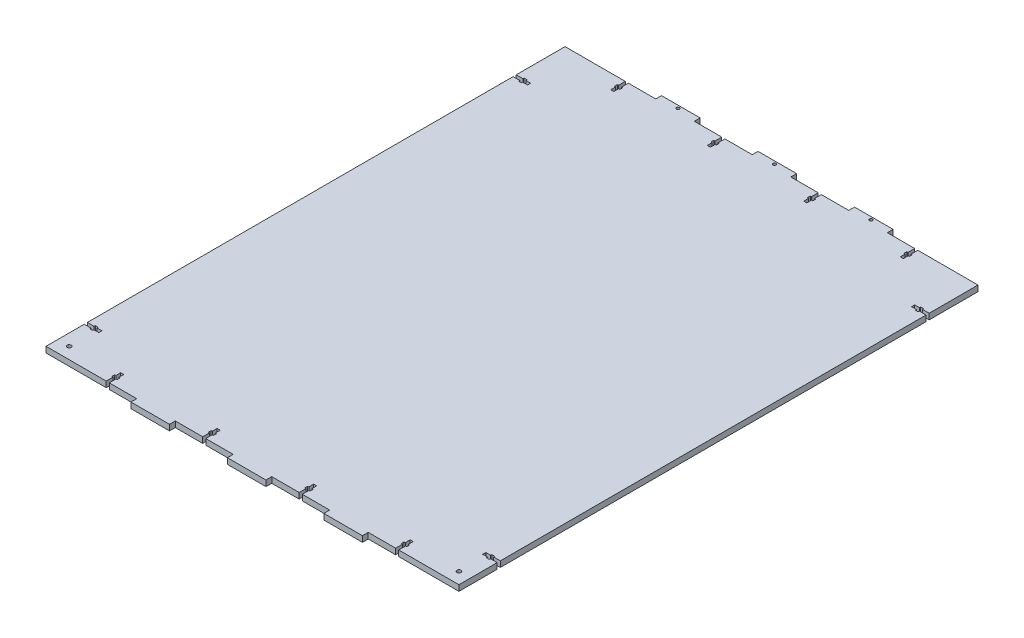
from build123d import *

# Parameters (mm, degrees)
SKETCH1_W           = 428
SKETCH1_H           = 538
BOSS_EXTRUDE1_DEPTH = 6
SKETCH2_W           = 40
SKETCH2_H           = 6
BOSS_EXTRUDE2_DEPTH = 6
SKETCH3_R           = 1.6
SKETCH3_R_2         = 2.1
CUT_EXTRUDE1_DEPTH  = 7


with BuildPart() as part:
    # Sketch1 → Boss-Extrude1 (new body)
    with BuildSketch(Plane(origin=(0, 0, 0), x_dir=(1, 0, 0), z_dir=(0, 1, 0))):
        Rectangle(SKETCH1_W, SKETCH1_H)
    extrude(amount=BOSS_EXTRUDE1_DEPTH)

    # Sketch2 → Boss-Extrude2 (add)
    with BuildSketch(Plane.XZ):
        with Locations((-100, 272)):
            Rectangle(SKETCH2_W, SKETCH2_H)
        with Locations((0, 272)):
            Rectangle(SKETCH2_W, SKETCH2_H)
        with Locations((100, 272)):
            Rectangle(SKETCH2_W, SKETCH2_H)
        with Locations((100, -272)):
            Rectangle(SKETCH2_W, SKETCH2_H)
        with Locations((0, -272)):
            Rectangle(SKETCH2_W, SKETCH2_H)
        with Locations((-100, -272)):
            Rectangle(SKETCH2_W, SKETCH2_H)
    extrude(amount=-BOSS_EXTRUDE2_DEPTH)

    # Sketch3 → Cut-Extrude1 (cut, through all)
    with BuildSketch(Plane.XZ):
        Polygon((204, -219.55), (207, -219.55), (207, -218.35), (214, -218.35), (214, -215.15), (207, -215.15), (207, -213.95), (204, -213.95), (204, -215.15), (199, -215.15), (199, -218.35), (204, -218.35), align=None)
        Polygon((-214, 229.35), (-214, 226.15), (-207, 226.15), (-207, 224.95), (-204, 224.95), (-204, 226.15), (-199, 226.15), (-199, 229.35), (-204, 229.35), (-204, 230.55), (-207, 230.55), (-207, 229.35), align=None)
        Polygon((-214, -215.15), (-214, -218.35), (-207, -218.35), (-207, -219.55), (-204, -219.55), (-204, -218.35), (-199, -218.35), (-199, -215.15), (-204, -215.15), (-204, -213.95), (-207, -213.95), (-207, -215.15), align=None)
        Polygon((207, 226.15), (214, 226.15), (214, 229.35), (207, 229.35), (207, 230.55), (204, 230.55), (204, 229.35), (199, 229.35), (199, 226.15), (204, 226.15), (204, 224.95), (207, 224.95), align=None)
        Polygon((151.6, 254), (151.6, 259), (152.8, 259), (152.8, 262), (151.6, 262), (151.6, 269), (148.4, 269), (148.4, 262), (147.2, 262), (147.2, 259), (148.4, 259), (148.4, 254), align=None)
        Polygon((51.6, 254), (51.6, 259), (52.8, 259), (52.8, 262), (51.6, 262), (51.6, 269), (48.4, 269), (48.4, 262), (47.2, 262), (47.2, 259), (48.4, 259), (48.4, 254), align=None)
        Polygon((-48.4, 254), (-48.4, 259), (-47.2, 259), (-47.2, 262), (-48.4, 262), (-48.4, 269), (-51.6, 269), (-51.6, 262), (-52.8, 262), (-52.8, 259), (-51.6, 259), (-51.6, 254), align=None)
        Polygon((-148.4, 254), (-148.4, 259), (-147.2, 259), (-147.2, 262), (-148.4, 262), (-148.4, 269), (-151.6, 269), (-151.6, 262), (-152.8, 262), (-152.8, 259), (-151.6, 259), (-151.6, 254), align=None)
        Polygon((-148.4, -254), (-151.6, -254), (-151.6, -259), (-152.8, -259), (-152.8, -262), (-151.6, -262), (-151.6, -269), (-148.4, -269), (-148.4, -262), (-147.2, -262), (-147.2, -259), (-148.4, -259), align=None)
        Polygon((-48.4, -254), (-51.6, -254), (-51.6, -259), (-52.8, -259), (-52.8, -262), (-51.6, -262), (-51.6, -269), (-48.4, -269), (-48.4, -262), (-47.2, -262), (-47.2, -259), (-48.4, -259), align=None)
        Polygon((51.6, -254), (48.4, -254), (48.4, -259), (47.2, -259), (47.2, -262), (48.4, -262), (48.4, -269), (51.6, -269), (51.6, -262), (52.8, -262), (52.8, -259), (51.6, -259), align=None)
        Polygon((151.6, -254), (148.4, -254), (148.4, -259), (147.2, -259), (147.2, -262), (148.4, -262), (148.4, -269), (151.6, -269), (151.6, -262), (152.8, -262), (152.8, -259), (151.6, -259), align=None)
        with Locations((-100, -272)):
            Circle(SKETCH3_R)
        with Locations((0, -272)):
            Circle(SKETCH3_R)
        with Locations((100, -272)):
            Circle(SKETCH3_R)
        with Locations((202, 257)):
            Circle(SKETCH3_R_2)
        with Locations((-202, 257)):
            Circle(SKETCH3_R_2)
    extrude(amount=-CUT_EXTRUDE1_DEPTH, mode=Mode.SUBTRACT)


solid = part.part
